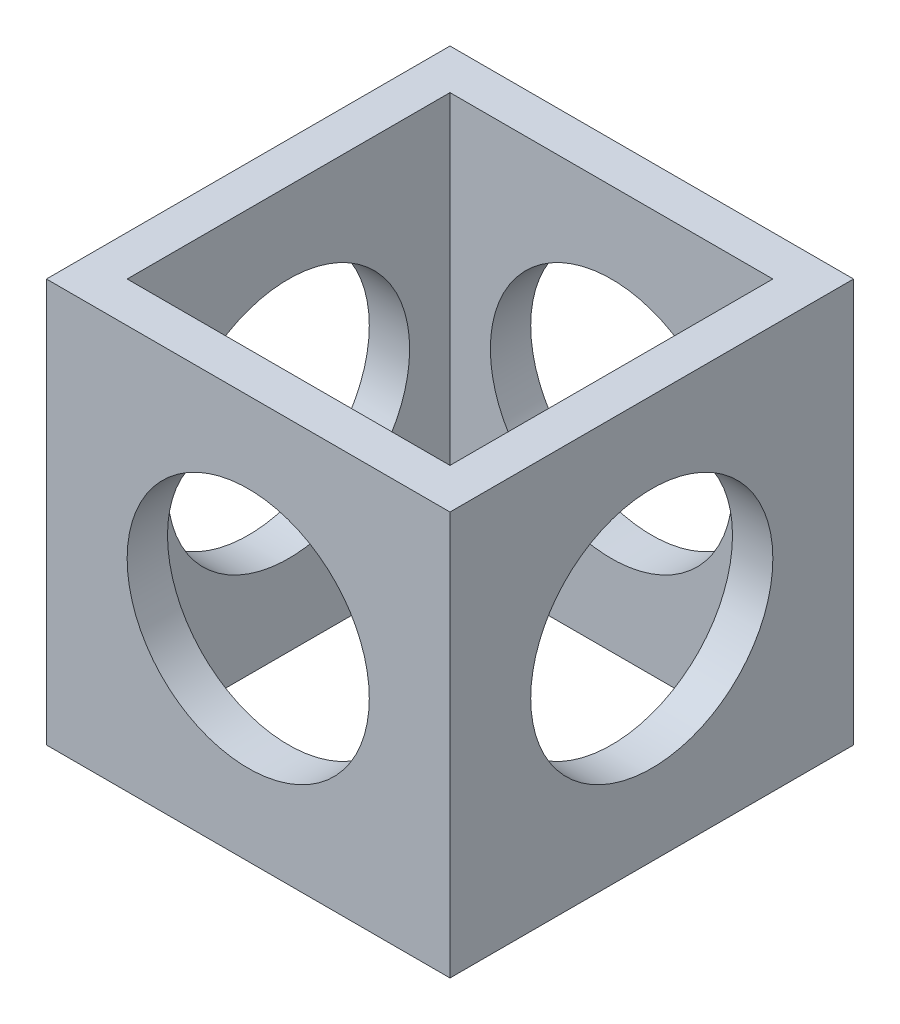
from build123d import *

# Parameters (mm, degrees)
SKETCH1_W           = 50
SKETCH1_H           = 50
BOSS_EXTRUDE1_DEPTH = 50
SKETCH2_W           = 40
SKETCH2_H           = 40
CUT_EXTRUDE1_DEPTH  = 51
SKETCH4_R           = 15
CUT_EXTRUDE2_DEPTH  = 51


with BuildPart() as part:
    # Sketch1 → Boss-Extrude1 (new body)
    with BuildSketch(Plane(origin=(0, 0, 0), x_dir=(0, 0, -1), z_dir=(1, 0, 0))):
        Rectangle(SKETCH1_W, SKETCH1_H)
    extrude(amount=-BOSS_EXTRUDE1_DEPTH)

    # Sketch2 → Cut-Extrude1 (cut, through all)
    with BuildSketch(Plane(origin=(0, 25, 0), x_dir=(1, 0, 0), z_dir=(0, 1, 0))):
        with Locations((-25, 0)):
            Rectangle(SKETCH2_W, SKETCH2_H)
    extrude(amount=-CUT_EXTRUDE1_DEPTH, mode=Mode.SUBTRACT)

    # Sketch4 → Cut-Extrude2 (cut, through all)
    with BuildSketch(Plane(origin=(0, 0, 0), x_dir=(0, 0, -1), z_dir=(1, 0, 0))):
        Circle(SKETCH4_R)
    cut_extrude2 = extrude(amount=-CUT_EXTRUDE2_DEPTH, mode=Mode.SUBTRACT)

    # Mirror4: Cut-Extrude2 across plane
    add(cut_extrude2.mirror(Plane(origin=(-12.5, 0, -12.5), x_dir=(-0.707106781, 0, 0.707106781), z_dir=(0.707106781, 0, 0.707106781))), mode=Mode.SUBTRACT)


solid = part.part
